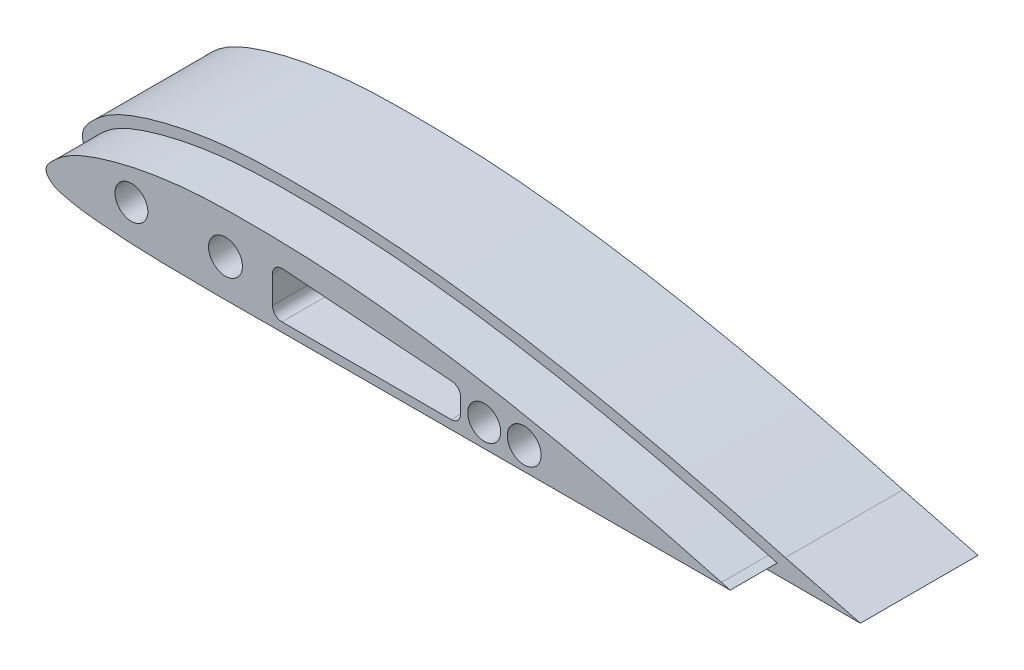
from build123d import *

# Parameters (mm, degrees)
BOSS_EXTRUDE1_DEPTH = 25
BOSS_EXTRUDE2_DEPTH = 10
SKETCH4_R           = 3.6
CUT_EXTRUDE1_DEPTH  = 15
CUT_EXTRUDE3_DEPTH  = 36.0000001
FILLET1_R           = 2
SKETCH7_R           = 3.6
CUT_EXTRUDE5_DEPTH  = 10
CUT_EXTRUDE8_DEPTH  = 10
SKETCH12_R          = 3
CUT_EXTRUDE9_DEPTH  = 36.0000001
SKETCH13_R          = 3.5
CUT_EXTRUDE10_DEPTH = 10


with BuildPart() as part:
    # Sketch1 → Boss-Extrude1 (new body)
    with BuildSketch(Plane.XY):
        with BuildLine():
            Line((283.511495539, 5), (300, 5))
            Line((300, 5), (284.042903706, 9.104747331))
            add(Edge.make_bspline(
                [(284.042903706, 9.104747331), (281.018182266, 9.934448854), (274.970241175, 11.587890144), (262.79473022, 14.694313575), (247.491233442, 18.223533255), (228.976842031, 21.827934197), (213.382227838, 24.050161757), (200.838041916, 25.278245027), (191.375164043, 25.84368073), (181.929184267, 26.032743059), (174.045462371, 26.006042455), (167.684560321, 25.672470841), (162.907071513, 25.190814957), (158.171526473, 24.473110108), (154.249506507, 23.687741972), (151.126214943, 22.914370362), (148.803354307, 22.253406079), (146.502749028, 21.520325526), (144.195506174, 20.673935797), (142.285508901, 19.825366279), (140.77889876, 19.023820525), (139.657125815, 18.333005403), (138.579850724, 17.555983513), (137.573588148, 16.694586159), (136.840207592, 16.017655424), (136.197854945, 15.377866917), (135.703534611, 14.819080651), (135.209742419, 14.135691171), (134.834254268, 13.401317293), (134.617222415, 12.613247879), (134.564446521, 11.925922824), (134.632536136, 11.28393571), (134.823945829, 10.646033518), (135.050340736, 10.171503439), (135.402372545, 9.594086183), (135.88903595, 9.014014422), (136.503170411, 8.453671438), (137.189145836, 7.961236195), (137.934436655, 7.567322512), (138.88780816, 7.188002663), (139.999875909, 6.893687057), (141.119343981, 6.633570858), (142.339822694, 6.362465545), (143.566669583, 6.141759686), (145.201441111, 5.905638988), (147.208483131, 5.701996633), (149.554876985, 5.501790345), (152.720125659, 5.26351314), (156.664468718, 5.054606644), (161.394596408, 4.900355455), (166.115091131, 4.822052763), (170.826943763, 4.793504207), (175.53175108, 4.796790347), (181.792624225, 4.819444757), (189.6120847, 4.833292228), (199.004221884, 4.846116121), (208.393622069, 4.86447262), (217.783394427, 4.881553097), (230.302961737, 4.904736774), (245.952266215, 4.932077157), (264.731689616, 4.966403983), (277.251584666, 4.988082326), (283.511495539, 5)],
                knots=[0, 0, 0, 0, 0.03125, 0.0625, 0.125, 0.1875, 0.25, 0.28125, 0.3125, 0.34375, 0.375, 0.390625, 0.40625, 0.421875, 0.4375, 0.4453125, 0.453125, 0.4609375, 0.46875, 0.4765625, 0.48046875, 0.484375, 0.48828125, 0.4921875, 0.49609375, 0.498046875, 0.5, 0.501953125, 0.50390625, 0.504882812, 0.505859375, 0.506835938, 0.5078125, 0.508789062, 0.509765625, 0.51171875, 0.513671875, 0.515625, 0.517578125, 0.51953125, 0.5234375, 0.52734375, 0.53125, 0.53515625, 0.5390625, 0.546875, 0.5546875, 0.5625, 0.578125, 0.59375, 0.609375, 0.625, 0.640625, 0.65625, 0.6875, 0.71875, 0.75, 0.78125, 0.8125, 0.875, 0.9375, 1, 1, 1, 1], degree=3))
        make_face()
    extrude(amount=BOSS_EXTRUDE1_DEPTH)

    # Sketch2 → Boss-Extrude2 (add)
    with BuildSketch(Plane.XY.offset(25)):
        with BuildLine():
            Line((283.513833939, 7.175995097), (283.507687929, 6.999996376))
            add(Edge.make_bspline(
                [(283.513833939, 7.175995097), (281.571904317, 7.70867951), (278.660206217, 8.507455383), (273.803739367, 9.80565678), (267.97829695, 11.312028336), (262.142072687, 12.749566544), (255.333625933, 14.349614888), (248.529613694, 15.873152186), (237.829834978, 18.074534328), (225.176932927, 20.37341773), (211.498139299, 22.244459108), (201.708098139, 23.182256892), (192.898920041, 23.758329904), (187.019418903, 23.949968323), (180.15742652, 24.013831631), (175.249730247, 24.004272513), (170.338530232, 23.831174476), (165.415432247, 23.461746301), (161.471844656, 22.973662362), (156.530765352, 22.131833865), (152.563801607, 21.260194487), (148.61875975, 20.114158122), (145.614430375, 19.098876324), (143.118037069, 18.029614893), (141.123958755, 16.9205006), (139.709137736, 15.918497883), (138.639345116, 14.95805949), (137.821338999, 14.184645576), (137.299185859, 13.616573145), (136.909881104, 13.064885766), (136.694719435, 12.628458505), (136.558079327, 12.1110472), (136.590613242, 11.681743145), (136.726425076, 11.304303594), (136.875964941, 11.002707479), (137.185565184, 10.559851475), (137.664667186, 10.08522865), (138.418575368, 9.535630723), (139.499520541, 9.074027829), (140.887462138, 8.7435984), (142.345331504, 8.400407996), (143.807660076, 8.124702473), (145.759448913, 7.848569845), (148.205744396, 7.622105414), (151.139287771, 7.379908489), (157.009672693, 7.006958204), (166.81242185, 6.755142002), (180.53899309, 6.823541362), (193.287044915, 6.836259813), (208.977590991, 6.865360258), (224.668134499, 6.894381263), (240.35868648, 6.922785416), (251.145938886, 6.941204055), (259.971867913, 6.958006911), (268.797802015, 6.972991946), (276.643073115, 6.987898539), (281.546370172, 6.996262401), (283.507687929, 6.999996376)],
                knots=[0, 0, 0, 0, 0.020105055, 0.030145261, 0.050190794, 0.080180377, 0.09015591, 0.120020101, 0.149793491, 0.199219015, 0.248395636, 0.287604023, 0.297393127, 0.336534715, 0.346322474, 0.365907652, 0.385530879, 0.395375762, 0.415192461, 0.425184025, 0.445412191, 0.455710779, 0.466190959, 0.477054504, 0.482786727, 0.488945835, 0.494316033, 0.497126416, 0.500187368, 0.502000869, 0.503849971, 0.505020137, 0.507317905, 0.507986558, 0.509023586, 0.510668219, 0.513358348, 0.515715812, 0.519949385, 0.524973188, 0.5299544, 0.534903202, 0.539824123, 0.549630394, 0.559425369, 0.569214167, 0.608355933, 0.657307127, 0.70626328, 0.735636871, 0.813966735, 0.862922864, 0.892296527, 0.921670208, 0.951043871, 0.980417552, 1, 1, 1, 1], degree=3))
        make_face()
    extrude(amount=BOSS_EXTRUDE2_DEPTH)

    # Sketch4 → Cut-Extrude1 (cut)
    with BuildSketch(Plane.XY.offset(35)):
        with Locations((175, 15)):
            Circle(SKETCH4_R)
        with Locations((238.513833939, 12)):
            Circle(SKETCH4_R)
    extrude(amount=-CUT_EXTRUDE1_DEPTH, mode=Mode.SUBTRACT)

    # Sketch5 → Cut-Extrude3 (cut, through all)
    with BuildSketch(Plane.XY.offset(35)):
        Polygon((185, 19), (185, 9), (225, 9), (225, 16), align=None)
    extrude(amount=-CUT_EXTRUDE3_DEPTH, mode=Mode.SUBTRACT)

    # Fillet1
    fillet1_edges = [part.edges().sort_by_distance(p)[0] for p in [
        (185, 19, 17.5),
        (225, 16, 17.5),
        (225, 9, 17.5),
        (185, 9, 17.5),
    ]]
    fillet(fillet1_edges, radius=FILLET1_R)

    # Sketch7 → Cut-Extrude5 (cut)
    with BuildSketch(Plane.XY.offset(20)):
        with Locations((238.513833939, 12)):
            Circle(SKETCH7_R)
        with Locations((175, 15)):
            Circle(SKETCH7_R)
    extrude(amount=-CUT_EXTRUDE5_DEPTH, mode=Mode.SUBTRACT)

    # Sketch11 → Cut-Extrude8 (cut)
    with BuildSketch(Plane.XY.offset(35)):
        with BuildLine():
            Line((283.511495539, 5), (300, 5))
            Line((300, 5), (284.042903706, 9.104747331))
            add(Edge.make_bspline(
                [(284.042903706, 9.104747331), (281.018182266, 9.934448854), (274.970241175, 11.587890144), (262.79473022, 14.694313575), (247.491233442, 18.223533255), (228.976842031, 21.827934197), (213.382227838, 24.050161757), (200.838041916, 25.278245027), (191.375164043, 25.84368073), (181.929184267, 26.032743059), (174.045462371, 26.006042455), (167.684560321, 25.672470841), (162.907071513, 25.190814957), (158.171526473, 24.473110108), (154.249506507, 23.687741972), (151.126214943, 22.914370362), (148.803354307, 22.253406079), (146.502749028, 21.520325526), (144.195506174, 20.673935797), (142.285508901, 19.825366279), (140.77889876, 19.023820525), (139.657125815, 18.333005403), (138.579850724, 17.555983513), (137.573588148, 16.694586159), (136.840207592, 16.017655424), (136.197854945, 15.377866917), (135.703534611, 14.819080651), (135.209742419, 14.135691171), (134.834254268, 13.401317293), (134.617222415, 12.613247879), (134.564446521, 11.925922824), (134.632536136, 11.28393571), (134.823945829, 10.646033518), (135.050340736, 10.171503439), (135.402372545, 9.594086183), (135.88903595, 9.014014422), (136.503170411, 8.453671438), (137.189145836, 7.961236195), (137.934436655, 7.567322512), (138.88780816, 7.188002663), (139.999875909, 6.893687057), (141.119343981, 6.633570858), (142.339822694, 6.362465545), (143.566669583, 6.141759686), (145.201441111, 5.905638988), (147.208483131, 5.701996633), (149.554876985, 5.501790345), (152.720125659, 5.26351314), (156.664468718, 5.054606644), (161.394596408, 4.900355455), (166.115091131, 4.822052763), (170.826943763, 4.793504207), (175.53175108, 4.796790347), (181.792624225, 4.819444757), (189.6120847, 4.833292228), (199.004221884, 4.846116121), (208.393622069, 4.86447262), (217.783394427, 4.881553097), (230.302961737, 4.904736774), (245.952266215, 4.932077157), (264.731689616, 4.966403983), (277.251584666, 4.988082326), (283.511495539, 5)],
                knots=[0, 0, 0, 0, 0.03125, 0.0625, 0.125, 0.1875, 0.25, 0.28125, 0.3125, 0.34375, 0.375, 0.390625, 0.40625, 0.421875, 0.4375, 0.4453125, 0.453125, 0.4609375, 0.46875, 0.4765625, 0.48046875, 0.484375, 0.48828125, 0.4921875, 0.49609375, 0.498046875, 0.5, 0.501953125, 0.50390625, 0.504882812, 0.505859375, 0.506835938, 0.5078125, 0.508789062, 0.509765625, 0.51171875, 0.513671875, 0.515625, 0.517578125, 0.51953125, 0.5234375, 0.52734375, 0.53125, 0.53515625, 0.5390625, 0.546875, 0.5546875, 0.5625, 0.578125, 0.59375, 0.609375, 0.625, 0.640625, 0.65625, 0.6875, 0.71875, 0.75, 0.78125, 0.8125, 0.875, 0.9375, 1, 1, 1, 1], degree=3))
        make_face()
        with BuildLine():
            Line((280.513390523, 7.244526695), (282.311215859, 7.247715437))
            Line((282.311215859, 7.247715437), (280.44797449, 7.756537062))
            add(Edge.make_bspline(
                [(280.44797449, 7.756537062), (274.534465518, 9.371422441), (262.666278129, 12.456536483), (244.725070703, 16.500039954), (229.666461352, 19.35987636), (217.545749679, 21.180252708), (208.419827833, 22.292195861), (199.267169335, 23.141591681), (190.090470638, 23.633600144), (180.898070651, 23.789400172), (173.238558093, 23.733636136), (167.129206096, 23.369682896), (162.567763373, 22.874860039), (158.034150221, 22.16074902), (153.539248689, 21.236492218), (149.852487199, 20.234822881), (146.945230118, 19.292315286), (144.803545274, 18.48961438), (142.725540705, 17.546887534), (141.085684909, 16.598722592), (139.86978606, 15.703323679), (139.013550133, 14.961029981), (138.170437688, 14.182154097), (137.401074911, 13.373582652), (136.803307143, 12.444228231), (136.829882646, 11.451768694), (137.482568342, 10.565545947), (138.329478635, 9.869516572), (139.329659123, 9.407251793), (140.415272051, 9.107362954), (141.537321939, 8.847170661), (143.022070654, 8.512295915), (144.899414778, 8.203698196), (147.17695901, 7.963727425), (149.467563487, 7.767177325), (152.519466424, 7.531262629), (156.342190917, 7.321412147), (160.934174151, 7.162916123), (165.530029485, 7.079231042), (171.659516065, 7.034152237), (179.324124736, 7.062229579), (188.524155347, 7.082506373), (197.722784075, 7.093713479), (209.988077557, 7.117662613), (225.319649881, 7.145543289), (243.717600096, 7.178422958), (262.115483697, 7.211491555), (274.380756079, 7.23364945), (280.513390523, 7.244526695)],
                knots=[0.010352061, 0.010352061, 0.010352061, 0.010352061, 0.071582315, 0.132812569, 0.194042822, 0.224657949, 0.255273076, 0.285888203, 0.31650333, 0.347118457, 0.377733584, 0.393041148, 0.408348711, 0.423656275, 0.438963838, 0.454271402, 0.461925183, 0.469578965, 0.477232747, 0.484886529, 0.48871342, 0.49254031, 0.496367201, 0.500194092, 0.504020983, 0.507847874, 0.511674765, 0.515501656, 0.519328547, 0.523155437, 0.526982328, 0.530809219, 0.538463001, 0.546116783, 0.553770564, 0.561424346, 0.57673191, 0.592039473, 0.607347037, 0.6226546, 0.653269727, 0.683884854, 0.714499981, 0.745115108, 0.806345362, 0.867575616, 0.92880587, 0.990036124, 0.990036124, 0.990036124, 0.990036124], degree=3))
        make_face(mode=Mode.SUBTRACT)
    extrude(amount=-CUT_EXTRUDE8_DEPTH, mode=Mode.SUBTRACT)

    # Sketch12 → Cut-Extrude9 (cut, through all)
    with BuildSketch(Plane(origin=(0, 0, 0), x_dir=(-1, 0, 0), z_dir=(0, 0, -1))):
        with Locations((-154.999999999, 15)):
            Circle(SKETCH12_R)
        with Locations((-230.013833939, 12)):
            Circle(SKETCH12_R)
    extrude(amount=-CUT_EXTRUDE9_DEPTH, mode=Mode.SUBTRACT)

    # Sketch13 → Cut-Extrude10 (cut)
    with BuildSketch(Plane.XY.offset(35)):
        with Locations((154.999999999, 15)):
            Circle(SKETCH13_R)
        with Locations((230.013833939, 12)):
            Circle(SKETCH13_R)
    extrude(amount=-CUT_EXTRUDE10_DEPTH, mode=Mode.SUBTRACT)


solid = part.part
